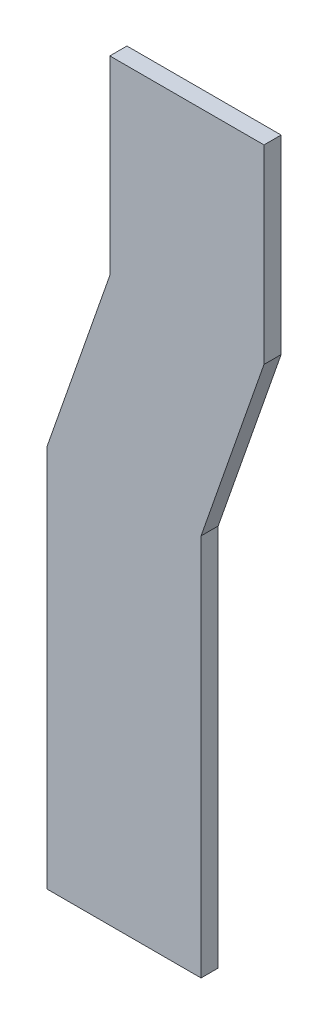
from build123d import *

# Parameters (mm, degrees)
BOSS_EXTRUDE1_DEPTH = 10


with BuildPart() as part:
    # Sketch1 → Boss-Extrude1 (new body, symmetric)
    with BuildSketch(Plane.XY):
        Polygon((0, 0), (180, 0), (180, -222), (106.514043336, -432.07800402), (106.514043336, -879.07800402), (-73.485956664, -879.07800402), (-73.485956664, -432.07800402), (0, -222), align=None)
    extrude(amount=BOSS_EXTRUDE1_DEPTH, both=True)


solid = part.part
